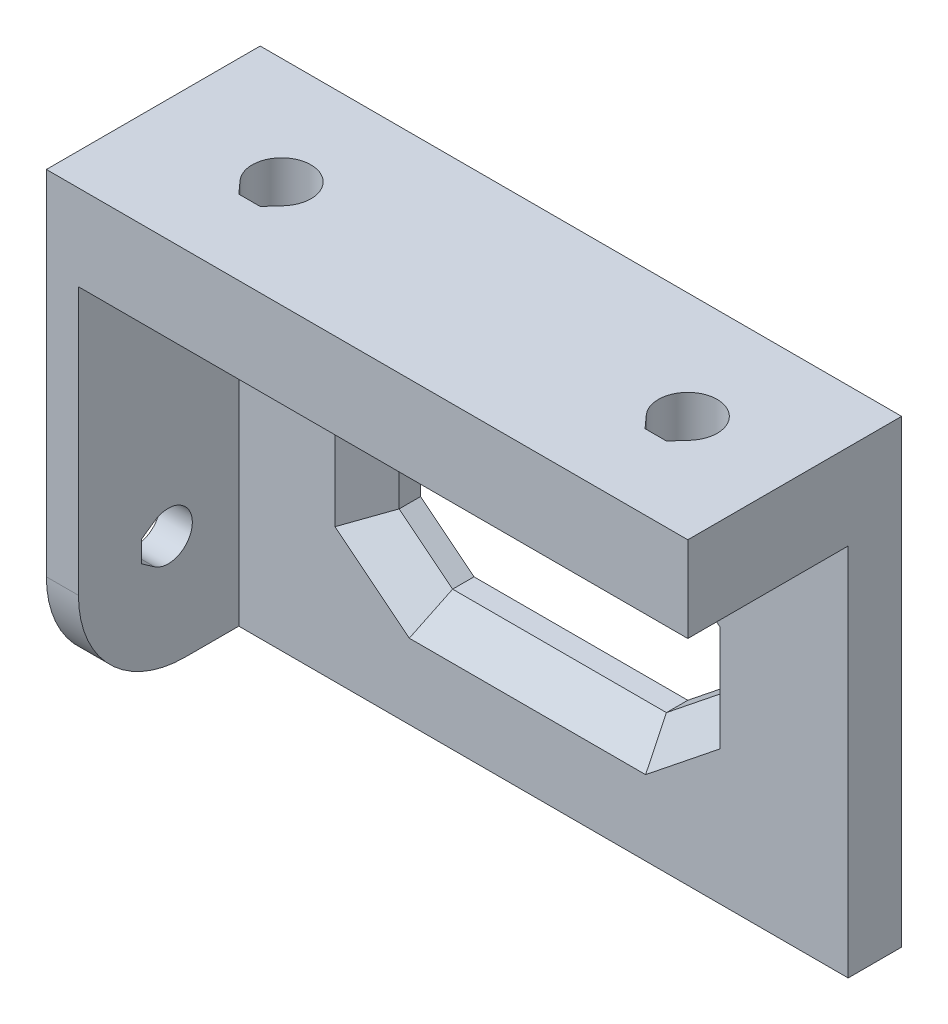
from build123d import *

# Parameters (mm, degrees)
CROQUIS1_W              = 60
CROQUIS1_H              = 35
CROQUIS1_W_2            = 30
CROQUIS1_H_2            = 15
SALIENTE_EXTRUIR1_DEPTH = 5
CHAFL_N2_SIZE           = 4
CHAFL_N2_SIZE2          = 5
CHAFL_N2_PART_2_SIZE    = 4
CHAFL_N2_PART_2_SIZE2   = 5
CHAFL_N3_SIZE           = 5
CHAFL_N3_SIZE2          = 4
CHAFL_N3_PART_2_SIZE    = 5
CHAFL_N3_PART_2_SIZE2   = 4
CHAFL_N1_SIZE           = 3
CROQUIS2_W              = 60
CROQUIS2_H              = 8
SALIENTE_EXTRUIR2_DEPTH = 20
CORTAR_EXTRUIR1_DEPTH   = 9
CROQUIS4_W              = 3
CROQUIS4_H              = 35
SALIENTE_EXTRUIR3_DEPTH = 15
CORTAR_EXTRUIR2_DEPTH   = 10
REDONDEO1_R             = 10


with BuildPart() as part:
    # Croquis1 → Saliente-Extruir1 (new body)
    with BuildSketch(Plane.XY):
        with Locations((30, 17.5)):
            Rectangle(CROQUIS1_W, CROQUIS1_H)
        with Locations((30, 17.5)):
            Rectangle(CROQUIS1_W_2, CROQUIS1_H_2, mode=Mode.SUBTRACT)
    extrude(amount=SALIENTE_EXTRUIR1_DEPTH)

    # Chaflán2
    chafl_n2_edges = [part.edges().sort_by_distance(p)[0] for p in [
        (15, 25, 2.5),
    ]]
    chafl_n2_side = [part.faces().sort_by_distance(p)[0] for p in [
        (15, 17.5, 2.5),
    ]]
    chamfer(chafl_n2_edges, length=CHAFL_N2_SIZE, length2=CHAFL_N2_SIZE2, reference=chafl_n2_side[0])

    # Chaflán2 part 2
    chafl_n2_part_2_edges = [part.edges().sort_by_distance(p)[0] for p in [
        (45, 10, 2.5),
    ]]
    chafl_n2_part_2_side = [part.faces().sort_by_distance(p)[0] for p in [
        (45, 17.5, 2.5),
    ]]
    chamfer(chafl_n2_part_2_edges, length=CHAFL_N2_PART_2_SIZE, length2=CHAFL_N2_PART_2_SIZE2, reference=chafl_n2_part_2_side[0])

    # Chaflán3
    chafl_n3_edges = [part.edges().sort_by_distance(p)[0] for p in [
        (15, 10, 2.5),
    ]]
    chafl_n3_side = [part.faces().sort_by_distance(p)[0] for p in [
        (27.5, 10, 2.5),
    ]]
    chamfer(chafl_n3_edges, length=CHAFL_N3_SIZE, length2=CHAFL_N3_SIZE2, reference=chafl_n3_side[0])

    # Chaflán3 part 2
    chafl_n3_part_2_edges = [part.edges().sort_by_distance(p)[0] for p in [
        (45, 25, 2.5),
    ]]
    chafl_n3_part_2_side = [part.faces().sort_by_distance(p)[0] for p in [
        (32.5, 25, 2.5),
    ]]
    chamfer(chafl_n3_part_2_edges, length=CHAFL_N3_PART_2_SIZE, length2=CHAFL_N3_PART_2_SIZE2, reference=chafl_n3_part_2_side[0])

    # Chaflán1
    chafl_n1_edges = [part.edges().sort_by_distance(p)[0] for p in [
        (45, 17.5, 5),
        (15, 17.5, 5),
        (42.5, 12, 5),
        (17.5, 23, 5),
        (30, 25, 5),
        (30, 10, 5),
        (42.5, 23, 5),
        (17.5, 12, 5),
    ]]
    chamfer(chafl_n1_edges, length=CHAFL_N1_SIZE)

    # Croquis2 → Saliente-Extruir2 (add)
    with BuildSketch(Plane(origin=(0, 0, 0), x_dir=(-1, 0, 0), z_dir=(0, 0, -1))):
        with Locations((-30, 39)):
            Rectangle(CROQUIS2_W, CROQUIS2_H)
    extrude(amount=-SALIENTE_EXTRUIR2_DEPTH)

    # Croquis3 → Cortar-Extruir1 (cut, through all)
    with BuildSketch(Plane.XZ.offset(-35)):
        with BuildLine():
            Line((9.955719163, 11.839406388), (11, 13))
            Line((11, 13), (13, 13))
            Line((13, 13), (14.044280837, 11.839406388))
            ThreePointArc((14.044280837, 11.839406388), (12, 7.25), (9.955719163, 11.839406388))
        make_face()
        with BuildLine():
            Line((47.955719163, 11.839406388), (49, 13))
            Line((49, 13), (51, 13))
            Line((51, 13), (52.044280837, 11.839406388))
            ThreePointArc((52.044280837, 11.839406388), (50, 7.25), (47.955719163, 11.839406388))
        make_face()
    extrude(amount=-CORTAR_EXTRUIR1_DEPTH, mode=Mode.SUBTRACT)

    # Croquis4 → Saliente-Extruir3 (add)
    with BuildSketch(Plane.XY.offset(5)):
        with Locations((1.5, 17.5)):
            Rectangle(CROQUIS4_W, CROQUIS4_H)
    extrude(amount=SALIENTE_EXTRUIR3_DEPTH)

    # Croquis5 → Cortar-Extruir2 (cut)
    with BuildSketch(Plane.ZY):
        with BuildLine():
            Line((12.886683465, 12.445791337), (14.1, 11.6))
            Line((14.1, 11.6), (14.1, 9.6))
            Line((14.1, 9.6), (12.886683465, 8.754208663))
            ThreePointArc((12.886683465, 8.754208663), (9.35, 10.6), (12.886683465, 12.445791337))
        make_face()
    extrude(amount=-CORTAR_EXTRUIR2_DEPTH, mode=Mode.SUBTRACT)

    # Redondeo1
    redondeo1_edges = [part.edges().sort_by_distance(p)[0] for p in [
        (1.5, 0, 20),
    ]]
    fillet(redondeo1_edges, radius=REDONDEO1_R)


solid = part.part
